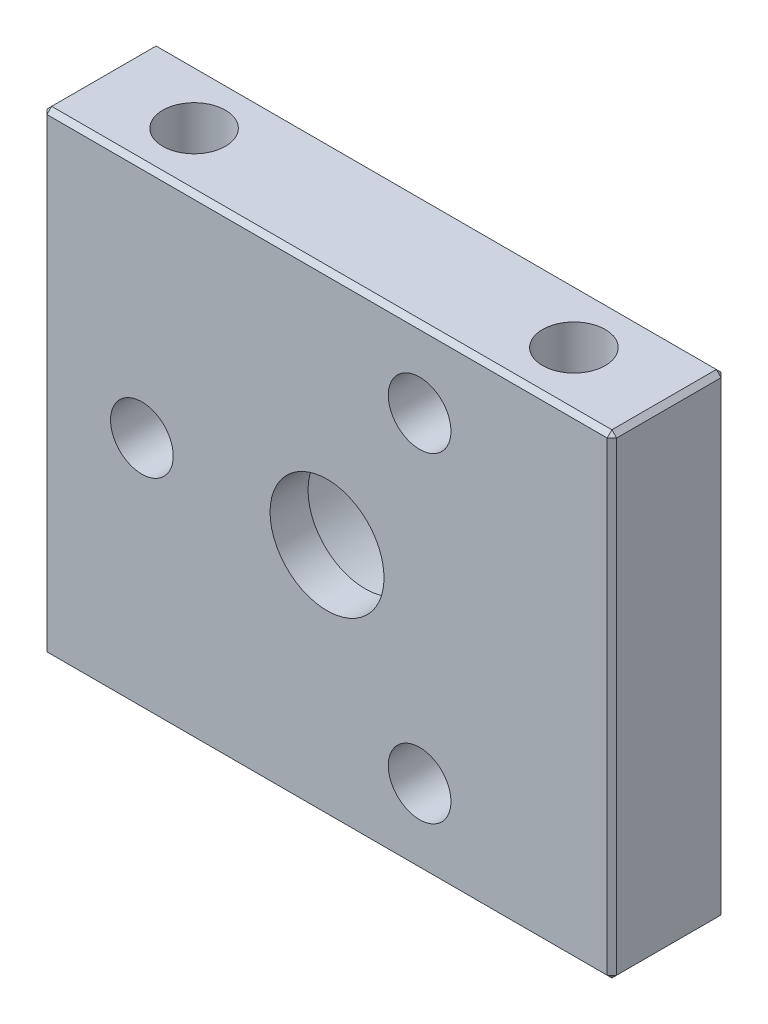
from build123d import *

# Parameters (mm, degrees)
SKETCH1_W                           = 30
SKETCH1_H                           = 6
EXTRUDE1_DEPTH                      = 25
SKETCH2_R                           = 5
CUT_EXTRUDE1_DEPTH                  = 4
SKETCH3_R                           = 3
CUT_EXTRUDE2_DEPTH                  = 12
M4X0_7_TAPPED_HOLE1_D               = 3.3
M4X0_7_TAPPED_HOLE1_DEPTH           = 10.3
M4X0_7_TAPPED_HOLE1_TIP             = 0.991420021
M4X0_7_TAPPED_HOLE1_ON_FACE_2_D     = 3.3
M4X0_7_TAPPED_HOLE1_ON_FACE_2_DEPTH = 10.3
M4X0_7_TAPPED_HOLE1_ON_FACE_2_TIP   = 0.991420021
CHAMFER2_SIZE                       = 0.25
M4X0_7_TAPPED_HOLE2_D               = 3.3
M4X0_7_TAPPED_HOLE2_DEPTH           = 10.1
M4X0_7_TAPPED_HOLE2_TIP             = 0.991420021


with BuildPart() as part:
    # Sketch1 → Extrude1 (new body)
    with BuildSketch(Plane(origin=(0, 0, 0), x_dir=(1, 0, 0), z_dir=(0, 1, 0))):
        Rectangle(SKETCH1_W, SKETCH1_H)
    extrude(amount=EXTRUDE1_DEPTH)

    # Sketch2 → Cut-Extrude1 (cut)
    with BuildSketch(Plane(origin=(0, 0, -3), x_dir=(-1, 0, 0), z_dir=(0, 0, -1))):
        with Locations((0, 12.5)):
            Circle(SKETCH2_R)
    extrude(amount=-CUT_EXTRUDE1_DEPTH, mode=Mode.SUBTRACT)

    # Sketch3 → Cut-Extrude2 (cut)
    with BuildSketch(Plane(origin=(0, 0, 1), x_dir=(-1, 0, 0), z_dir=(0, 0, -1))):
        with Locations((0, 12.5)):
            Circle(SKETCH3_R)
    extrude(amount=-CUT_EXTRUDE2_DEPTH, mode=Mode.SUBTRACT)

    # M4x0.7 Tapped Hole1
    with Locations(Plane(origin=(10, 25, 0), x_dir=(0, 0, 1), z_dir=(0, 1, 0))):
        with Locations((0, 0), (0, -20)):
            Hole(M4X0_7_TAPPED_HOLE1_D / 2, depth=M4X0_7_TAPPED_HOLE1_DEPTH)
            with Locations((0, 0, -(M4X0_7_TAPPED_HOLE1_DEPTH + M4X0_7_TAPPED_HOLE1_TIP / 2))):  # 118° drill point
                Cone(0, M4X0_7_TAPPED_HOLE1_D / 2, M4X0_7_TAPPED_HOLE1_TIP, mode=Mode.SUBTRACT)

    # M4x0.7 Tapped Hole1 on face 2
    with Locations(Plane(origin=(10, 0, 0), x_dir=(0, 0, -1), z_dir=(0, -1, 0))):
        with Locations((0, 0), (0, -20)):
            Hole(M4X0_7_TAPPED_HOLE1_ON_FACE_2_D / 2, depth=M4X0_7_TAPPED_HOLE1_ON_FACE_2_DEPTH)
            with Locations((0, 0, -(M4X0_7_TAPPED_HOLE1_ON_FACE_2_DEPTH + M4X0_7_TAPPED_HOLE1_ON_FACE_2_TIP / 2))):  # 118° drill point
                Cone(0, M4X0_7_TAPPED_HOLE1_ON_FACE_2_D / 2, M4X0_7_TAPPED_HOLE1_ON_FACE_2_TIP, mode=Mode.SUBTRACT)

    # Chamfer2
    chamfer2_edges = [part.edges().sort_by_distance(p)[0] for p in [
        (15, 25, 0),
        (0, 25, -3),
        (-15, 25, 0),
        (0, 0, -3),
        (15, 0, 0),
        (0, 0, 3),
        (-15, 0, 0),
        (0, 25, 3),
        (-15, 12.5, -3),
        (15, 12.5, -3),
        (15, 12.5, 3),
        (-15, 12.5, 3),
    ]]
    chamfer(chamfer2_edges, length=CHAMFER2_SIZE)

    # M4x0.7 Tapped Hole2
    with Locations(Plane(origin=(-9.75, 12.5, 3), x_dir=(1, 0, 0), z_dir=(0, 0, 1))):
        with Locations((0, 0), (14.625, -8.443747687), (14.625, 8.443747687)):
            Hole(M4X0_7_TAPPED_HOLE2_D / 2, depth=M4X0_7_TAPPED_HOLE2_DEPTH)
            with Locations((0, 0, -(M4X0_7_TAPPED_HOLE2_DEPTH + M4X0_7_TAPPED_HOLE2_TIP / 2))):  # 118° drill point
                Cone(0, M4X0_7_TAPPED_HOLE2_D / 2, M4X0_7_TAPPED_HOLE2_TIP, mode=Mode.SUBTRACT)


solid = part.part
